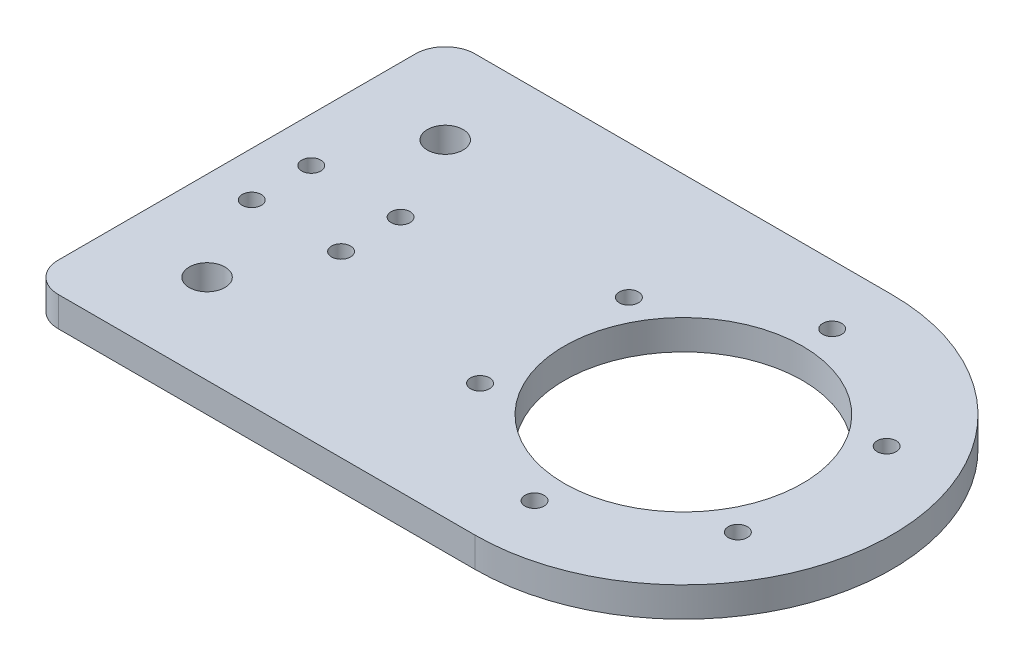
from build123d import *

# Parameters (mm, degrees)
SKETCH1_R           = 1.6
SKETCH1_R_2         = 20
SKETCH1_R_3         = 3
BOSS_EXTRUDE1_DEPTH = 5
FILLET1_R           = 5
SKETCH4_R           = 3.25
CUT_EXTRUDE2_DEPTH  = 1.5


with BuildPart() as part:
    # Sketch1 → Boss-Extrude1 (new body)
    with BuildSketch(Plane(origin=(0, 0, 0), x_dir=(1, 0, 0), z_dir=(0, 1, 0))):
        with BuildLine():
            Line((-75, 35), (0, 35))
            ThreePointArc((0, 35), (35, 0), (0, -35))
            Line((0, -35), (-75, -35))
            Line((-75, -35), (-75, 35))
        make_face()
        with Locations((0, 25)):
            Circle(SKETCH1_R, mode=Mode.SUBTRACT)
        with Locations((21.650635095, 12.5)):
            Circle(SKETCH1_R, mode=Mode.SUBTRACT)
        with Locations((21.650635095, -12.5)):
            Circle(SKETCH1_R, mode=Mode.SUBTRACT)
        with Locations((0, -25)):
            Circle(SKETCH1_R, mode=Mode.SUBTRACT)
        with Locations((-21.650635095, -12.5)):
            Circle(SKETCH1_R, mode=Mode.SUBTRACT)
        with Locations((-21.650635095, 12.5)):
            Circle(SKETCH1_R, mode=Mode.SUBTRACT)
        Circle(SKETCH1_R_2, mode=Mode.SUBTRACT)
        with Locations((-67.5, 5)):
            Circle(SKETCH1_R, mode=Mode.SUBTRACT)
        with Locations((-52.5, 5)):
            Circle(SKETCH1_R, mode=Mode.SUBTRACT)
        with Locations((-52.5, -5)):
            Circle(SKETCH1_R, mode=Mode.SUBTRACT)
        with Locations((-67.5, -5)):
            Circle(SKETCH1_R, mode=Mode.SUBTRACT)
        with Locations((-60, 20)):
            Circle(SKETCH1_R_3, mode=Mode.SUBTRACT)
        with Locations((-60, -20)):
            Circle(SKETCH1_R_3, mode=Mode.SUBTRACT)
    extrude(amount=BOSS_EXTRUDE1_DEPTH)

    # Fillet1
    fillet1_edges = [part.edges().sort_by_distance(p)[0] for p in [
        (-75, 2.5, -35),
        (-75, 2.5, 35),
    ]]
    fillet(fillet1_edges, radius=FILLET1_R)

    # Sketch4 → Cut-Extrude2 (cut)
    with BuildSketch(Plane.XZ):
        with Locations((0, 25)):
            Circle(SKETCH4_R)
        with Locations((21.650635095, 12.5)):
            Circle(SKETCH4_R)
        with Locations((21.650635095, -12.5)):
            Circle(SKETCH4_R)
        with Locations((0, -25)):
            Circle(SKETCH4_R)
        with Locations((-21.650635095, -12.5)):
            Circle(SKETCH4_R)
        with Locations((-21.650635095, 12.5)):
            Circle(SKETCH4_R)
    extrude(amount=-CUT_EXTRUDE2_DEPTH, mode=Mode.SUBTRACT)


solid = part.part
